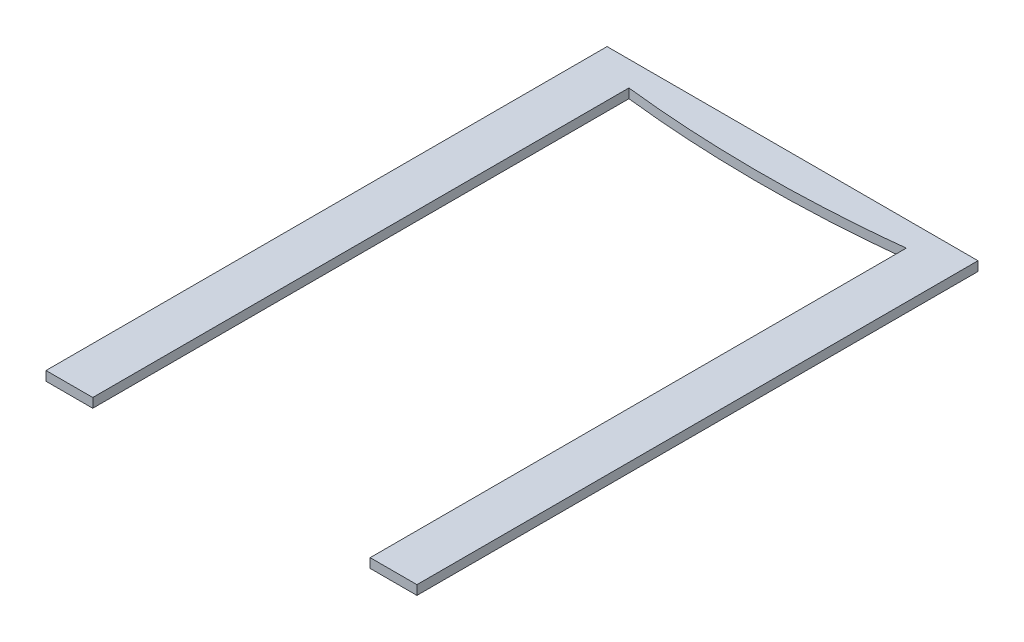
from build123d import *

# Parameters (mm, degrees)
BOSS_EXTRUDE1_DEPTH = 3


with BuildPart() as part:
    # Sketch1 → Boss-Extrude1 (new body)
    with BuildSketch(Plane(origin=(0, 0, 0), x_dir=(1, 0, 0), z_dir=(0, 1, 0))):
        with BuildLine():
            Line((-59.5, -90), (-59.5, 90))
            Line((-59.5, 90), (59.5, 90))
            Line((59.5, 90), (59.5, -90))
            Line((59.5, -90), (44.5, -90))
            Line((44.5, -90), (44.5, 82))
            add(Edge.make_bspline(
                [(-44.5, 82), (0, 77), (44.5, 82)],
                knots=[0, 0, 0, 1, 1, 1], degree=2))
            Line((-44.5, 82), (-44.5, -90))
            Line((-44.5, -90), (-59.5, -90))
        make_face()
    extrude(amount=BOSS_EXTRUDE1_DEPTH)


solid = part.part
